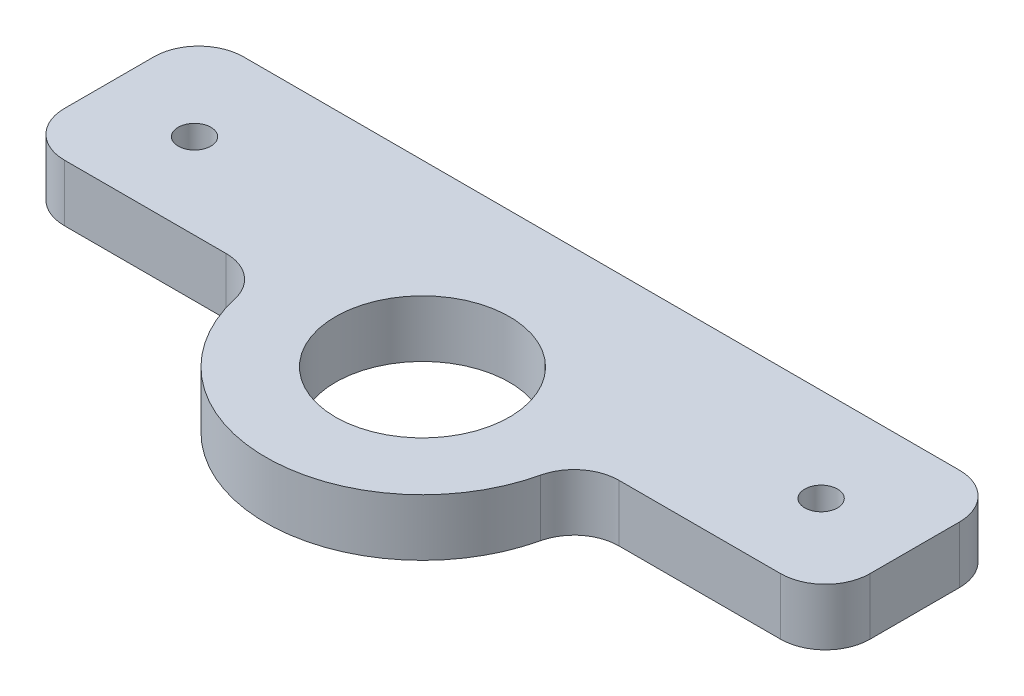
from build123d import *

# Parameters (mm, degrees)
BOSS_EXTRUDE1_DEPTH     = 6.35
F_3_4_CLEARANCE_HOLE1_D = 19.44624
FILLET1_R               = 5
F_6_CLEARANCE_HOLE1_D   = 3.6576


with BuildPart() as part:
    # Sketch1 → Boss-Extrude1 (new body)
    with BuildSketch(Plane(origin=(0, 0, 0), x_dir=(1, 0, 0), z_dir=(0, 1, 0))):
        with BuildLine():
            Line((-17.5, -10), (-45, -10))
            Line((-45, -10), (-45, 10))
            Line((-45, 10), (45, 10))
            Line((45, 10), (45, -10))
            Line((45, -10), (17.5, -10))
            ThreePointArc((17.5, -10), (0, -27.5), (-17.5, -10))
        make_face()
    extrude(amount=BOSS_EXTRUDE1_DEPTH)

    # 3/4 Clearance Hole1 (through all)
    with Locations(Plane(origin=(0, 6.35, 0), x_dir=(1, 0, 0), z_dir=(0, 1, 0))):
        with Locations((0, -10)):
            Hole(F_3_4_CLEARANCE_HOLE1_D / 2)

    # Fillet1
    fillet1_edges = [part.edges().sort_by_distance(p)[0] for p in [
        (-45, 3.175, -10),
        (45, 3.175, -10),
        (45, 3.175, 10),
        (17.5, 3.175, 10),
        (-17.5, 3.175, 10),
        (-45, 3.175, 10),
    ]]
    fillet(fillet1_edges, radius=FILLET1_R)

    # #6 Clearance Hole1 (through all)
    with Locations(Plane(origin=(0, 6.35, 0), x_dir=(1, 0, 0), z_dir=(0, 1, 0))):
        with Locations((-35, -0.465), (35, -0.465)):
            Hole(F_6_CLEARANCE_HOLE1_D / 2)


solid = part.part
